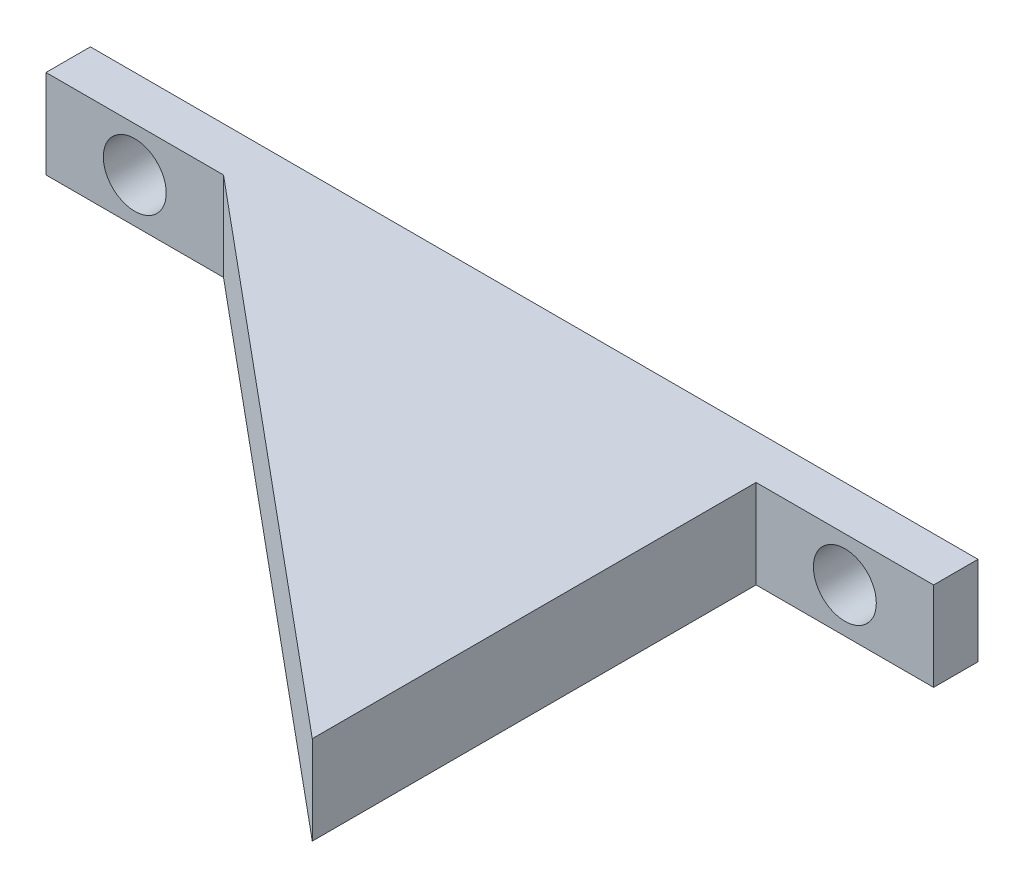
from build123d import *

# Parameters (mm, degrees)
SKETCH7_W           = 63.5
SKETCH7_H           = 3.175
BOSS_EXTRUDE4_DEPTH = 3.175
SKETCH8_R           = 2.2499955
CUT_EXTRUDE3_DEPTH  = 4.175
BOSS_EXTRUDE5_DEPTH = 6.35


with BuildPart() as part:
    # Sketch7 → Boss-Extrude4 (new body, symmetric)
    with BuildSketch(Plane(origin=(0, 0, 0), x_dir=(1, 0, 0), z_dir=(0, 1, 0))):
        Rectangle(SKETCH7_W, SKETCH7_H)
    extrude(amount=BOSS_EXTRUDE4_DEPTH, both=True)

    # Sketch8 → Cut-Extrude3 (cut, through all)
    with BuildSketch(Plane.XY.offset(1.5875)):
        with Locations((-25.4, 0)):
            Circle(SKETCH8_R)
        with Locations((25.4, 0)):
            Circle(SKETCH8_R)
    extrude(amount=-CUT_EXTRUDE3_DEPTH, mode=Mode.SUBTRACT)

    # Sketch9 → Boss-Extrude5 (add)
    with BuildSketch(Plane(origin=(0, 3.175, 0), x_dir=(1, 0, 0), z_dir=(0, 1, 0))):
        Polygon((19.05, -1.5875), (19.05, -33.3375), (-19.05, -1.5875), align=None)
    extrude(amount=-BOSS_EXTRUDE5_DEPTH)


solid = part.part
